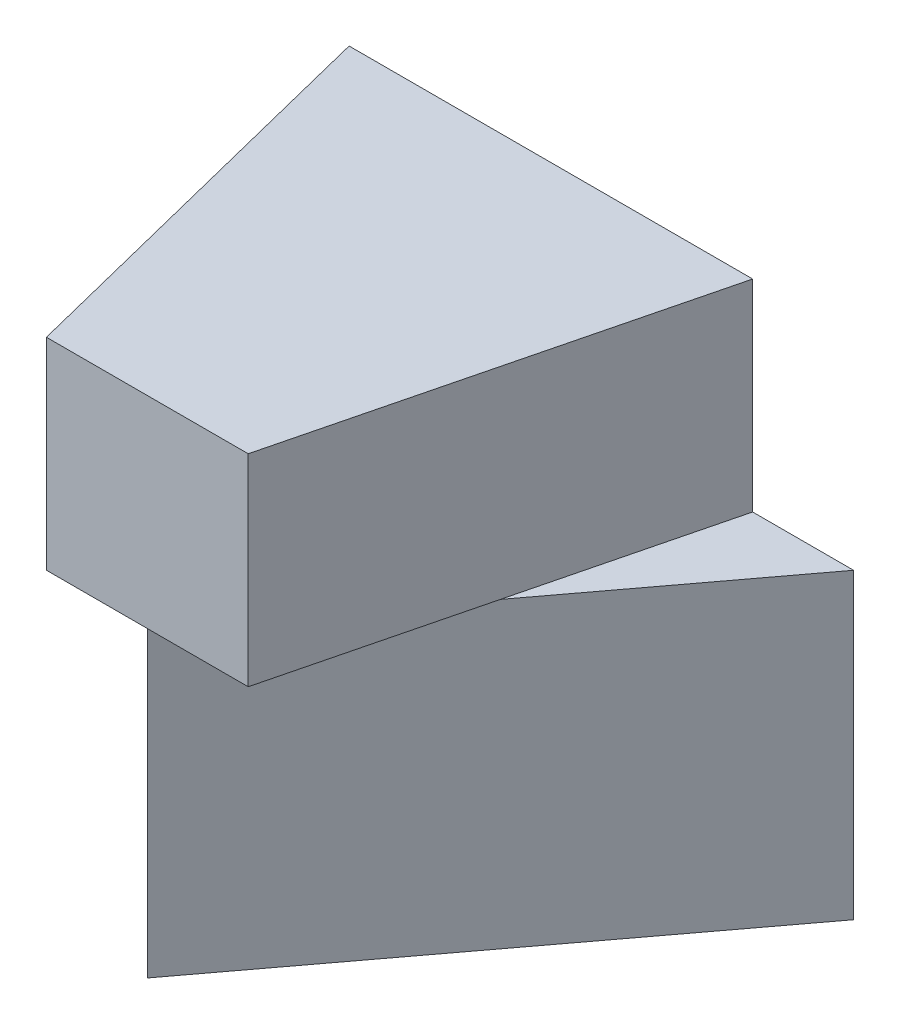
from build123d import *

# Parameters (mm, degrees)
BOSS_EXTRUDE1_DEPTH = 3
BOSS_EXTRUDE2_DEPTH = 2


with BuildPart() as part:
    # Sketch1 → Boss-Extrude1 (new body)
    with BuildSketch(Plane(origin=(0, 0, 0), x_dir=(1, 0, 0), z_dir=(0, 1, 0))):
        Polygon((0, 0), (-3, 4), (3, 4), align=None)
    extrude(amount=BOSS_EXTRUDE1_DEPTH)

    # Sketch2 → Boss-Extrude2 (add)
    with BuildSketch(Plane(origin=(0, 3, 0), x_dir=(1, 0, 0), z_dir=(0, 1, 0))):
        Polygon((2, 4), (1, 0), (-1, 0), (-2, 4), align=None)
    extrude(amount=BOSS_EXTRUDE2_DEPTH)


solid = part.part
